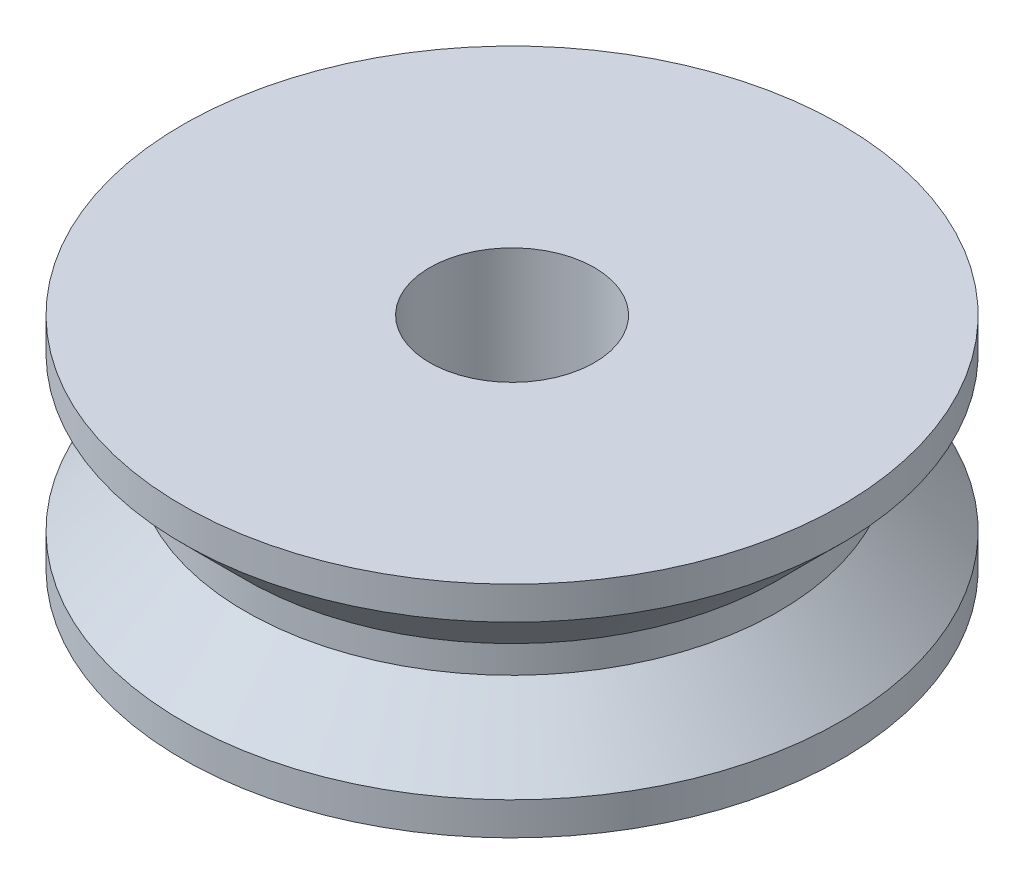
from build123d import *


with BuildPart() as part:
    # Esboço1 → Revolução1 (revolve)
    with BuildSketch(Plane.XY):
        Polygon((1.5, 0), (1.5, 4), (6, 4), (6, 3.4), (4.85, 2.25), (4.85, 1.75), (6, 0.6), (6, 0), align=None)
    revolve(axis=Axis((0, 0, 0), (0, 1, 0)))


solid = part.part
